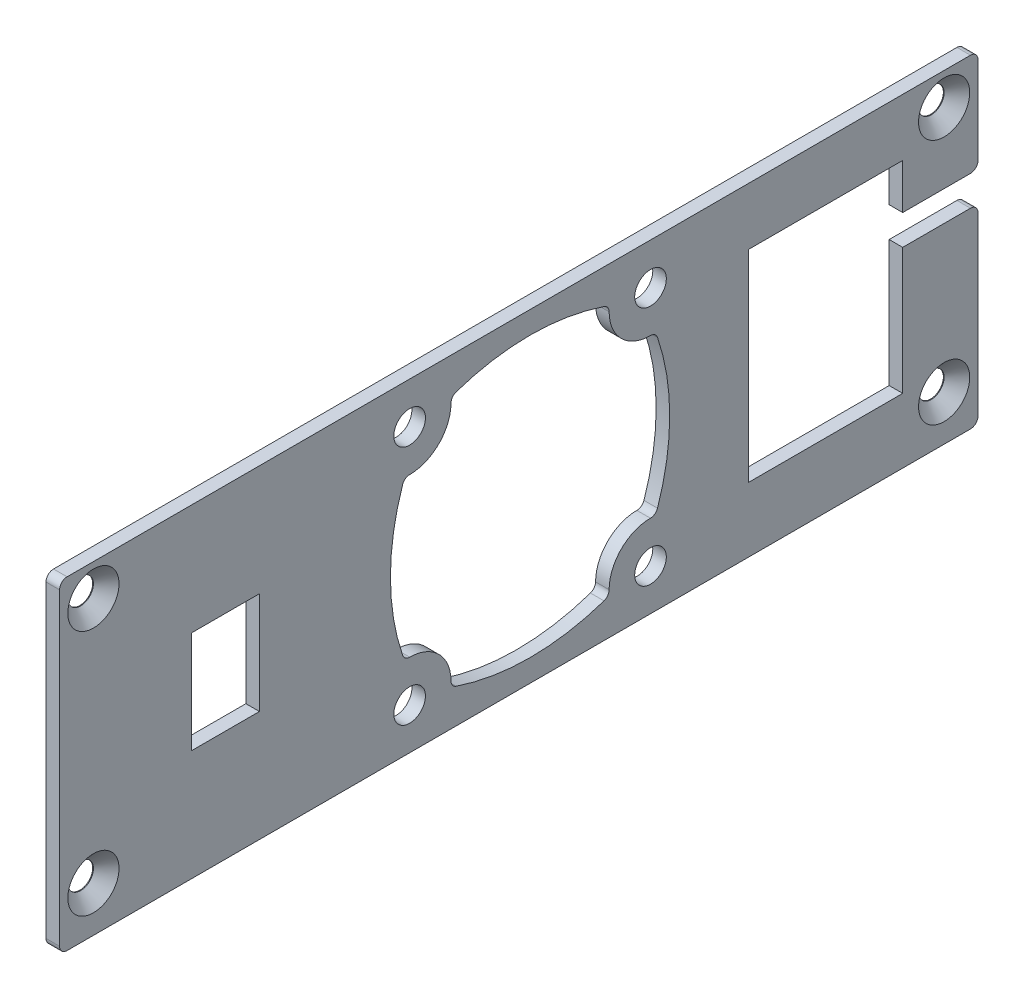
from build123d import *

# Parameters (mm, degrees)
SKETCH1_W                                    = 122
SKETCH1_H                                    = 43
BOSS_EXTRUDE1_DEPTH                          = 1.8
SKETCH2_W                                    = 9.05
SKETCH2_H                                    = 13.55
CUT_EXTRUDE1_DEPTH                           = 1.8
CSK_FOR_M3_COUNTERSUNK_FLAT_HEAD_SCR_2_COUNT = 2
CSK_FOR_M3_COUNTERSUNK_FLAT_HEAD_SCR_2_PITCH = 32.75
CSK_FOR_M3_COUNTERSUNK_FLAT_HEAD_SCR_3_COUNT = 2
CSK_FOR_M3_COUNTERSUNK_FLAT_HEAD_SCR_3_PITCH = 117.650169996
CSK_FOR_M3_COUNTERSUNK_FLAT_HEAD_SCR_4_COUNT = 2
CSK_FOR_M3_COUNTERSUNK_FLAT_HEAD_SCR_4_PITCH = 113
CUT_EXTRUDE2_DEPTH                           = 1.8
FILLET1_R                                    = 1
F_4_2_4_2_DIAMETER_HOLE1_D                   = 4.2
F_4_2_4_2_DIAMETER_HOLE1_DEPTH               = 1.8
F_4_2_4_2_DIAMETER_HOLE1_TIP                 = 1.2618073
CUT_EXTRUDE3_DEPTH                           = 1.8


with BuildPart() as part:
    # Sketch1 → Boss-Extrude1 (new body)
    with BuildSketch(Plane(origin=(0, 0, 0), x_dir=(0, 0, -1), z_dir=(1, 0, 0))):
        Rectangle(SKETCH1_W, SKETCH1_H)
    extrude(amount=BOSS_EXTRUDE1_DEPTH)

    # Sketch2 → Cut-Extrude1 (cut)
    with BuildSketch(Plane(origin=(1.8, 0, 0), x_dir=(0, 0, -1), z_dir=(1, 0, 0))):
        with Locations((-38.975, 0.005)):
            Rectangle(SKETCH2_W, SKETCH2_H)
    extrude(amount=-CUT_EXTRUDE1_DEPTH, mode=Mode.SUBTRACT)

    # Sketch3 → CSK for M3 Countersunk Flat Head Screw1 (revolve, cut)
    with BuildSketch(Plane(origin=(1.8, -15.5, 56.5), x_dir=(0, 0, -1), z_dir=(0, 1, 0))):
        Polygon((0, 0), (0, 1.8), (1.7, 1.8), (1.7, 1.7), (3.4, 0), align=None)
    csk_for_m3_countersunk_flat_head_screw1 = revolve(axis=Axis((8.15, -15.5, 56.5), (-1, 0, 0)), mode=Mode.SUBTRACT)

    # CSK for M3 Countersunk Flat Head Scr 2: CSK for M3 Countersunk Flat Head Screw1 ×2
    with Locations(*[(0, i * CSK_FOR_M3_COUNTERSUNK_FLAT_HEAD_SCR_2_PITCH, 0) for i in range(1, CSK_FOR_M3_COUNTERSUNK_FLAT_HEAD_SCR_2_COUNT)]):
        add(csk_for_m3_countersunk_flat_head_screw1, mode=Mode.SUBTRACT)

    # CSK for M3 Countersunk Flat Head Scr 3: CSK for M3 Countersunk Flat Head Screw1 ×2
    with Locations(*[Vector(0, 0.278367639, -0.9604746) * (i * CSK_FOR_M3_COUNTERSUNK_FLAT_HEAD_SCR_3_PITCH) for i in range(1, CSK_FOR_M3_COUNTERSUNK_FLAT_HEAD_SCR_3_COUNT)]):
        add(csk_for_m3_countersunk_flat_head_screw1, mode=Mode.SUBTRACT)

    # CSK for M3 Countersunk Flat Head Scr 4: CSK for M3 Countersunk Flat Head Screw1 ×2
    with Locations(*[(0, 0, -i * CSK_FOR_M3_COUNTERSUNK_FLAT_HEAD_SCR_4_PITCH) for i in range(1, CSK_FOR_M3_COUNTERSUNK_FLAT_HEAD_SCR_4_COUNT)]):
        add(csk_for_m3_countersunk_flat_head_screw1, mode=Mode.SUBTRACT)

    # Sketch5 → Cut-Extrude2 (cut)
    with BuildSketch(Plane(origin=(1.8, 0, 0), x_dir=(0, 0, -1), z_dir=(1, 0, 0))):
        Polygon((30.5, -12.9), (51, -12.9), (51, 3.9), (61, 3.9), (61, 7.9), (51, 7.9), (51, 13.9), (30.5, 13.9), align=None)
    extrude(amount=-CUT_EXTRUDE2_DEPTH, mode=Mode.SUBTRACT)

    # Fillet1
    fillet1_edges = [part.edges().sort_by_distance(p)[0] for p in [
        (0.9, 7.9, -61),
        (0.9, 3.9, -61),
        (0.9, 21.5, 61),
        (0.9, 21.5, -61),
        (0.9, -21.5, -61),
        (0.9, -21.5, 61),
    ]]
    fillet(fillet1_edges, radius=FILLET1_R)

    # Ø4.2 (4.2) Diameter Hole1
    with Locations(Plane(origin=(1.8, 0, 0), x_dir=(0, 0, -1), z_dir=(1, 0, 0))):
        with Locations((-14.5, 16), (17.5, 16), (17.5, -16), (-14.5, -16)):
            Hole(F_4_2_4_2_DIAMETER_HOLE1_D / 2, depth=F_4_2_4_2_DIAMETER_HOLE1_DEPTH)
            with Locations((0, 0, -(F_4_2_4_2_DIAMETER_HOLE1_DEPTH + F_4_2_4_2_DIAMETER_HOLE1_TIP / 2))):  # 118° drill point
                Cone(0, F_4_2_4_2_DIAMETER_HOLE1_D / 2, F_4_2_4_2_DIAMETER_HOLE1_TIP, mode=Mode.SUBTRACT)

    # Sketch8 → Cut-Extrude3 (cut)
    with BuildSketch(Plane(origin=(1.8, 0, 0), x_dir=(0, 0, -1), z_dir=(1, 0, 0))):
        with BuildLine():
            ThreePointArc((12.000022812, 15.984159355), (13.610912703, 12.110912703), (17.484159355, 10.500022812))
            ThreePointArc((17.484159355, 10.500022812), (18.064905248, 10.312049545), (18.428192241, 9.821516873))
            ThreePointArc((18.428192241, 9.821516873), (20.05, 0), (18.428192241, -9.821516873))
            ThreePointArc((18.428192241, -9.821516873), (18.064905248, -10.312049545), (17.484159355, -10.500022812))
            ThreePointArc((17.484159355, -10.500022812), (13.610912703, -12.110912703), (12.000022812, -15.984159355))
            ThreePointArc((12.000022812, -15.984159355), (11.812049545, -16.564905248), (11.321516873, -16.928192241))
            ThreePointArc((11.321516873, -16.928192241), (1.5, -18.55), (-8.321516873, -16.928192241))
            ThreePointArc((-8.321516873, -16.928192241), (-8.812049545, -16.564905248), (-9.000022812, -15.984159355))
            ThreePointArc((-9.000022812, -15.984159355), (-10.610912703, -12.110912703), (-14.484159355, -10.500022812))
            ThreePointArc((-14.484159355, -10.500022812), (-15.064905248, -10.312049545), (-15.428192241, -9.821516873))
            ThreePointArc((-15.428192241, -9.821516873), (-17.05, 0), (-15.428192241, 9.821516873))
            ThreePointArc((-15.428192241, 9.821516873), (-15.064905248, 10.312049545), (-14.484159355, 10.500022812))
            ThreePointArc((-14.484159355, 10.500022812), (-10.610912703, 12.110912703), (-9.000022812, 15.984159355))
            ThreePointArc((-9.000022812, 15.984159355), (-8.812049545, 16.564905248), (-8.321516873, 16.928192241))
            ThreePointArc((-8.321516873, 16.928192241), (1.5, 18.55), (11.321516873, 16.928192241))
            ThreePointArc((11.321516873, 16.928192241), (11.812049545, 16.564905248), (12.000022812, 15.984159355))
        make_face()
    extrude(amount=-CUT_EXTRUDE3_DEPTH, mode=Mode.SUBTRACT)


solid = part.part
